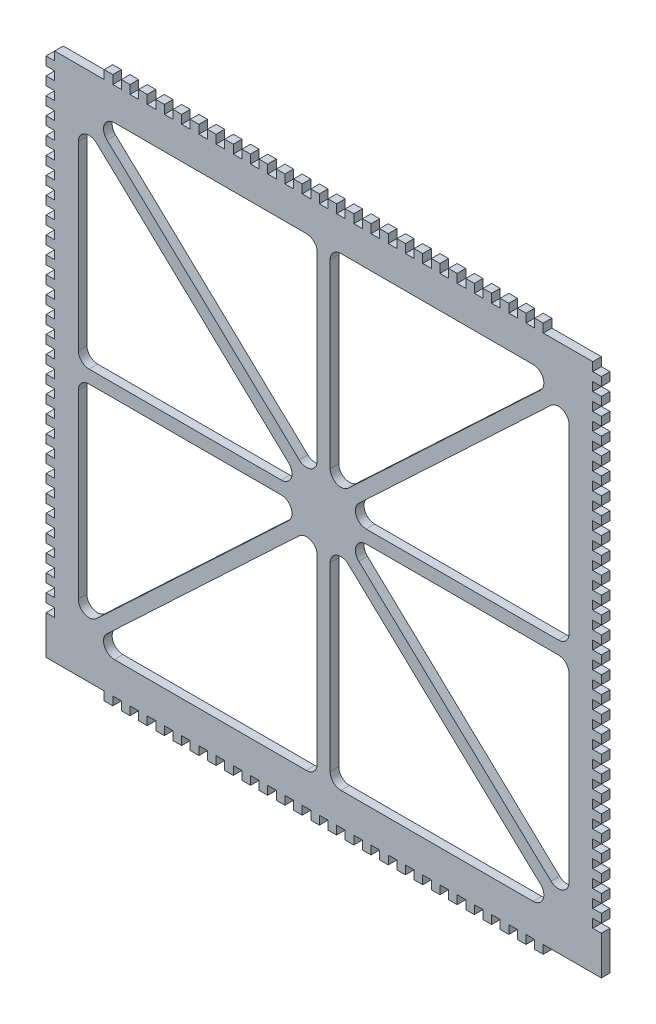
from build123d import *

# Parameters (mm, degrees)
SKETCH1_W           = 258
SKETCH1_H           = 246
BOSS_EXTRUDE1_DEPTH = 4
SKETCH2_W           = 4
SKETCH2_H           = 4
CUT_EXTRUDE1_DEPTH  = 4
SKETCH3_W           = 4
SKETCH3_H           = 4
BOSS_EXTRUDE2_DEPTH = 4


with BuildPart() as part:
    # Sketch1 → Boss-Extrude1 (new body)
    with BuildSketch(Plane.XY):
        Rectangle(SKETCH1_W, SKETCH1_H)
        with BuildLine():
            Line((-97.282138158, 108), (-8, 108))
            ThreePointArc((-8, 108), (-4.464466094, 106.535533906), (-3, 103))
            Line((-3, 103), (-3, 18.943186596))
            ThreePointArc((-3, 18.943186596), (-6.017197597, 14.353143608), (-11.427397853, 15.30272729))
            Line((-11.427397853, 15.30272729), (-100.70953601, 99.359540694))
            ThreePointArc((-100.70953601, 99.359540694), (-101.929841705, 104.843597498), (-97.282138158, 108))
        make_face(mode=Mode.SUBTRACT)
        with BuildLine():
            Line((-105.572602147, 95.69727271), (-16.29046399, 11.640459306))
            ThreePointArc((-16.29046399, 11.640459306), (-15.070158295, 6.156402502), (-19.717861842, 3))
            Line((-19.717861842, 3), (-109, 3))
            ThreePointArc((-109, 3), (-112.535533906, 4.464466094), (-114, 8))
            Line((-114, 8), (-114, 92.056813404))
            ThreePointArc((-114, 92.056813404), (-110.982802403, 96.646856392), (-105.572602147, 95.69727271))
        make_face(mode=Mode.SUBTRACT)
        with BuildLine():
            Line((8, 108), (97.282138158, 108))
            ThreePointArc((97.282138158, 108), (101.929841705, 104.843597498), (100.70953601, 99.359540694))
            Line((100.70953601, 99.359540694), (11.427397853, 15.30272729))
            ThreePointArc((11.427397853, 15.30272729), (6.017197597, 14.353143608), (3, 18.943186596))
            Line((3, 18.943186596), (3, 103))
            ThreePointArc((3, 103), (4.464466094, 106.535533906), (8, 108))
        make_face(mode=Mode.SUBTRACT)
        with BuildLine():
            Line((105.572602147, 95.69727271), (16.29046399, 11.640459306))
            ThreePointArc((16.29046399, 11.640459306), (15.070158295, 6.156402502), (19.717861842, 3))
            Line((19.717861842, 3), (109, 3))
            ThreePointArc((109, 3), (112.535533906, 4.464466094), (114, 8))
            Line((114, 8), (114, 92.056813404))
            ThreePointArc((114, 92.056813404), (110.982802403, 96.646856392), (105.572602147, 95.69727271))
        make_face(mode=Mode.SUBTRACT)
        with BuildLine():
            Line((-114, -8), (-114, -92.056813404))
            ThreePointArc((-114, -92.056813404), (-110.982802403, -96.646856392), (-105.572602147, -95.69727271))
            Line((-105.572602147, -95.69727271), (-16.29046399, -11.640459306))
            ThreePointArc((-16.29046399, -11.640459306), (-15.070158295, -6.156402502), (-19.717861842, -3))
            Line((-19.717861842, -3), (-109, -3))
            ThreePointArc((-109, -3), (-112.535533906, -4.464466094), (-114, -8))
        make_face(mode=Mode.SUBTRACT)
        with BuildLine():
            Line((114, -8), (114, -92.056813404))
            ThreePointArc((114, -92.056813404), (110.982802403, -96.646856392), (105.572602147, -95.69727271))
            Line((105.572602147, -95.69727271), (16.29046399, -11.640459306))
            ThreePointArc((16.29046399, -11.640459306), (15.070158295, -6.156402502), (19.717861842, -3))
            Line((19.717861842, -3), (109, -3))
            ThreePointArc((109, -3), (112.535533906, -4.464466094), (114, -8))
        make_face(mode=Mode.SUBTRACT)
        with BuildLine():
            Line((11.427397853, -15.30272729), (100.70953601, -99.359540694))
            ThreePointArc((100.70953601, -99.359540694), (101.929841705, -104.843597498), (97.282138158, -108))
            Line((97.282138158, -108), (8, -108))
            ThreePointArc((8, -108), (4.464466094, -106.535533906), (3, -103))
            Line((3, -103), (3, -18.943186596))
            ThreePointArc((3, -18.943186596), (6.017197597, -14.353143608), (11.427397853, -15.30272729))
        make_face(mode=Mode.SUBTRACT)
        with BuildLine():
            Line((-3, -18.943186596), (-3, -103))
            ThreePointArc((-3, -103), (-4.464466094, -106.535533906), (-8, -108))
            Line((-8, -108), (-97.282138158, -108))
            ThreePointArc((-97.282138158, -108), (-101.929841705, -104.843597498), (-100.70953601, -99.359540694))
            Line((-100.70953601, -99.359540694), (-11.427397853, -15.30272729))
            ThreePointArc((-11.427397853, -15.30272729), (-6.017197597, -14.353143608), (-3, -18.943186596))
        make_face(mode=Mode.SUBTRACT)
    extrude(amount=BOSS_EXTRUDE1_DEPTH)

    # Sketch2 → Cut-Extrude1 (cut)
    with BuildSketch(Plane.XY.offset(4)):
        with Locations((-127, -31)):
            Rectangle(SKETCH2_W, SKETCH2_H)
        with Locations((-127, -103)):
            Rectangle(SKETCH2_W, SKETCH2_H)
        with Locations((-127, 105)):
            Rectangle(SKETCH2_W, SKETCH2_H)
        with Locations((-127, 97)):
            Rectangle(SKETCH2_W, SKETCH2_H)
        with Locations((-127, 89)):
            Rectangle(SKETCH2_W, SKETCH2_H)
        with Locations((-127, 81)):
            Rectangle(SKETCH2_W, SKETCH2_H)
        with Locations((-127, 73)):
            Rectangle(SKETCH2_W, SKETCH2_H)
        with Locations((-127, 65)):
            Rectangle(SKETCH2_W, SKETCH2_H)
        with Locations((-127, 57)):
            Rectangle(SKETCH2_W, SKETCH2_H)
        with Locations((-127, 49)):
            Rectangle(SKETCH2_W, SKETCH2_H)
        with Locations((-127, 41)):
            Rectangle(SKETCH2_W, SKETCH2_H)
        with Locations((-127, 33)):
            Rectangle(SKETCH2_W, SKETCH2_H)
        with Locations((-127, 25)):
            Rectangle(SKETCH2_W, SKETCH2_H)
        with Locations((-127, 17)):
            Rectangle(SKETCH2_W, SKETCH2_H)
        with Locations((-127, 9)):
            Rectangle(SKETCH2_W, SKETCH2_H)
        with Locations((-127, 1)):
            Rectangle(SKETCH2_W, SKETCH2_H)
        with Locations((-127, -7)):
            Rectangle(SKETCH2_W, SKETCH2_H)
        with Locations((-127, -15)):
            Rectangle(SKETCH2_W, SKETCH2_H)
        with Locations((-127, -23)):
            Rectangle(SKETCH2_W, SKETCH2_H)
        with Locations((-127, 121)):
            Rectangle(SKETCH2_W, SKETCH2_H)
        with Locations((127, 121)):
            Rectangle(SKETCH2_W, SKETCH2_H)
        with Locations((127, -103)):
            Rectangle(SKETCH2_W, SKETCH2_H)
        with Locations((127, -95)):
            Rectangle(SKETCH2_W, SKETCH2_H)
        with Locations((127, -87)):
            Rectangle(SKETCH2_W, SKETCH2_H)
        with Locations((127, -79)):
            Rectangle(SKETCH2_W, SKETCH2_H)
        with Locations((127, -71)):
            Rectangle(SKETCH2_W, SKETCH2_H)
        with Locations((127, -63)):
            Rectangle(SKETCH2_W, SKETCH2_H)
        with Locations((-127, 113)):
            Rectangle(SKETCH2_W, SKETCH2_H)
        with Locations((127, -55)):
            Rectangle(SKETCH2_W, SKETCH2_H)
        with Locations((127, -47)):
            Rectangle(SKETCH2_W, SKETCH2_H)
        with Locations((127, -39)):
            Rectangle(SKETCH2_W, SKETCH2_H)
        with Locations((127, -31)):
            Rectangle(SKETCH2_W, SKETCH2_H)
        with Locations((127, 113)):
            Rectangle(SKETCH2_W, SKETCH2_H)
        with Locations((127, -23)):
            Rectangle(SKETCH2_W, SKETCH2_H)
        with Locations((127, -15)):
            Rectangle(SKETCH2_W, SKETCH2_H)
        with Locations((127, -7)):
            Rectangle(SKETCH2_W, SKETCH2_H)
        with Locations((127, 1)):
            Rectangle(SKETCH2_W, SKETCH2_H)
        with Locations((127, 9)):
            Rectangle(SKETCH2_W, SKETCH2_H)
        with Locations((127, 17)):
            Rectangle(SKETCH2_W, SKETCH2_H)
        with Locations((-127, -39)):
            Rectangle(SKETCH2_W, SKETCH2_H)
        with Locations((-127, -47)):
            Rectangle(SKETCH2_W, SKETCH2_H)
        with Locations((-127, -55)):
            Rectangle(SKETCH2_W, SKETCH2_H)
        with Locations((-127, -63)):
            Rectangle(SKETCH2_W, SKETCH2_H)
        with Locations((-127, -71)):
            Rectangle(SKETCH2_W, SKETCH2_H)
        with Locations((127, 25)):
            Rectangle(SKETCH2_W, SKETCH2_H)
        with Locations((127, 33)):
            Rectangle(SKETCH2_W, SKETCH2_H)
        with Locations((127, 41)):
            Rectangle(SKETCH2_W, SKETCH2_H)
        with Locations((127, 49)):
            Rectangle(SKETCH2_W, SKETCH2_H)
        with Locations((127, 57)):
            Rectangle(SKETCH2_W, SKETCH2_H)
        with Locations((127, 65)):
            Rectangle(SKETCH2_W, SKETCH2_H)
        with Locations((-127, -79)):
            Rectangle(SKETCH2_W, SKETCH2_H)
        with Locations((-127, -87)):
            Rectangle(SKETCH2_W, SKETCH2_H)
        with Locations((-127, -95)):
            Rectangle(SKETCH2_W, SKETCH2_H)
        with Locations((127, 73)):
            Rectangle(SKETCH2_W, SKETCH2_H)
        with Locations((127, 81)):
            Rectangle(SKETCH2_W, SKETCH2_H)
        with Locations((127, 89)):
            Rectangle(SKETCH2_W, SKETCH2_H)
        with Locations((127, 97)):
            Rectangle(SKETCH2_W, SKETCH2_H)
        with Locations((127, 105)):
            Rectangle(SKETCH2_W, SKETCH2_H)
    extrude(amount=-CUT_EXTRUDE1_DEPTH, mode=Mode.SUBTRACT)

    # Sketch3 → Boss-Extrude2 (add)
    with BuildSketch(Plane.XY.offset(4)):
        with Locations((-4, 125)):
            Rectangle(SKETCH3_W, SKETCH3_H)
        with Locations((-12, 125)):
            Rectangle(SKETCH3_W, SKETCH3_H)
        with Locations((-20, 125)):
            Rectangle(SKETCH3_W, SKETCH3_H)
        with Locations((-28, 125)):
            Rectangle(SKETCH3_W, SKETCH3_H)
        with Locations((-36, 125)):
            Rectangle(SKETCH3_W, SKETCH3_H)
        with Locations((-44, 125)):
            Rectangle(SKETCH3_W, SKETCH3_H)
        with Locations((-52, 125)):
            Rectangle(SKETCH3_W, SKETCH3_H)
        with Locations((-60, 125)):
            Rectangle(SKETCH3_W, SKETCH3_H)
        with Locations((-68, 125)):
            Rectangle(SKETCH3_W, SKETCH3_H)
        with Locations((-76, 125)):
            Rectangle(SKETCH3_W, SKETCH3_H)
        with Locations((-84, 125)):
            Rectangle(SKETCH3_W, SKETCH3_H)
        with Locations((-92, 125)):
            Rectangle(SKETCH3_W, SKETCH3_H)
        with Locations((-100, 125)):
            Rectangle(SKETCH3_W, SKETCH3_H)
        with Locations((100, 125)):
            Rectangle(SKETCH3_W, SKETCH3_H)
        with Locations((92, 125)):
            Rectangle(SKETCH3_W, SKETCH3_H)
        with Locations((84, 125)):
            Rectangle(SKETCH3_W, SKETCH3_H)
        with Locations((76, 125)):
            Rectangle(SKETCH3_W, SKETCH3_H)
        with Locations((68, 125)):
            Rectangle(SKETCH3_W, SKETCH3_H)
        with Locations((60, 125)):
            Rectangle(SKETCH3_W, SKETCH3_H)
        with Locations((52, 125)):
            Rectangle(SKETCH3_W, SKETCH3_H)
        with Locations((44, 125)):
            Rectangle(SKETCH3_W, SKETCH3_H)
        with Locations((36, 125)):
            Rectangle(SKETCH3_W, SKETCH3_H)
        with Locations((28, 125)):
            Rectangle(SKETCH3_W, SKETCH3_H)
        with Locations((20, 125)):
            Rectangle(SKETCH3_W, SKETCH3_H)
        with Locations((12, 125)):
            Rectangle(SKETCH3_W, SKETCH3_H)
        with Locations((4, 125)):
            Rectangle(SKETCH3_W, SKETCH3_H)
        with Locations((4, -125)):
            Rectangle(SKETCH3_W, SKETCH3_H)
        with Locations((12, -125)):
            Rectangle(SKETCH3_W, SKETCH3_H)
        with Locations((20, -125)):
            Rectangle(SKETCH3_W, SKETCH3_H)
        with Locations((28, -125)):
            Rectangle(SKETCH3_W, SKETCH3_H)
        with Locations((36, -125)):
            Rectangle(SKETCH3_W, SKETCH3_H)
        with Locations((44, -125)):
            Rectangle(SKETCH3_W, SKETCH3_H)
        with Locations((52, -125)):
            Rectangle(SKETCH3_W, SKETCH3_H)
        with Locations((60, -125)):
            Rectangle(SKETCH3_W, SKETCH3_H)
        with Locations((68, -125)):
            Rectangle(SKETCH3_W, SKETCH3_H)
        with Locations((76, -125)):
            Rectangle(SKETCH3_W, SKETCH3_H)
        with Locations((84, -125)):
            Rectangle(SKETCH3_W, SKETCH3_H)
        with Locations((92, -125)):
            Rectangle(SKETCH3_W, SKETCH3_H)
        with Locations((100, -125)):
            Rectangle(SKETCH3_W, SKETCH3_H)
        with Locations((-100, -125)):
            Rectangle(SKETCH3_W, SKETCH3_H)
        with Locations((-92, -125)):
            Rectangle(SKETCH3_W, SKETCH3_H)
        with Locations((-84, -125)):
            Rectangle(SKETCH3_W, SKETCH3_H)
        with Locations((-76, -125)):
            Rectangle(SKETCH3_W, SKETCH3_H)
        with Locations((-68, -125)):
            Rectangle(SKETCH3_W, SKETCH3_H)
        with Locations((-60, -125)):
            Rectangle(SKETCH3_W, SKETCH3_H)
        with Locations((-52, -125)):
            Rectangle(SKETCH3_W, SKETCH3_H)
        with Locations((-44, -125)):
            Rectangle(SKETCH3_W, SKETCH3_H)
        with Locations((-36, -125)):
            Rectangle(SKETCH3_W, SKETCH3_H)
        with Locations((-28, -125)):
            Rectangle(SKETCH3_W, SKETCH3_H)
        with Locations((-20, -125)):
            Rectangle(SKETCH3_W, SKETCH3_H)
        with Locations((-12, -125)):
            Rectangle(SKETCH3_W, SKETCH3_H)
        with Locations((-4, -125)):
            Rectangle(SKETCH3_W, SKETCH3_H)
    extrude(amount=-BOSS_EXTRUDE2_DEPTH)


solid = part.part
